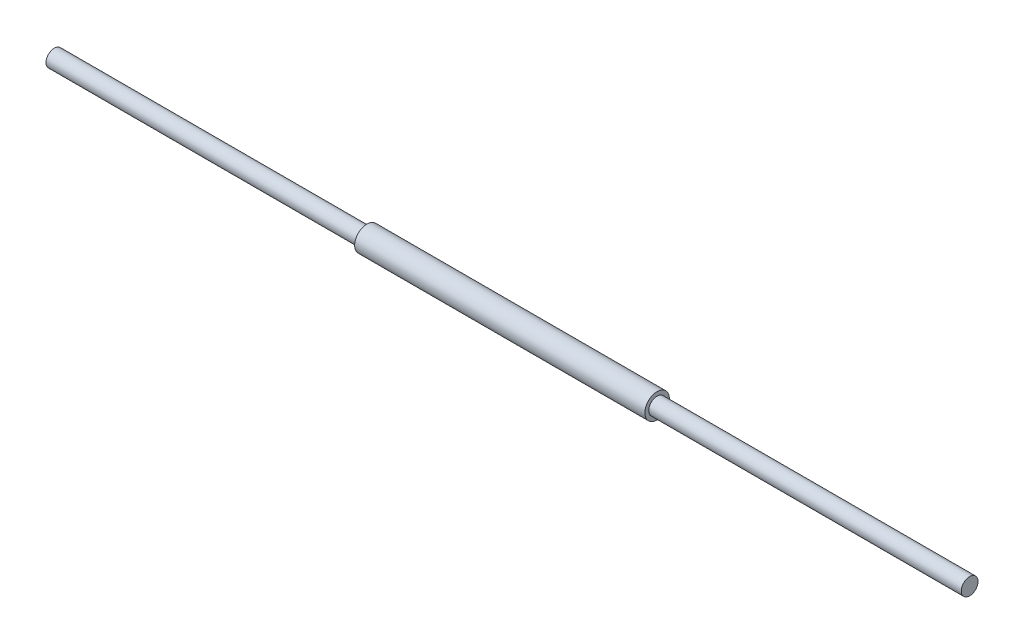
from build123d import *


with BuildPart() as part:
    # Sketch1 → Revolve1 (revolve)
    with BuildSketch(Plane(origin=(0, 0, 0), x_dir=(1, 0, 0), z_dir=(0, 1, 0))):
        Polygon((-82.55, 4.7625), (-82.55, 6.985), (82.55, 6.985), (82.55, 4.7625), (260.35, 4.7625), (260.35, 0), (-260.35, 0), (-260.35, 4.7625), align=None)
    revolve(axis=Axis((-260.35, 0, 0), (1, 0, 0)))


solid = part.part
